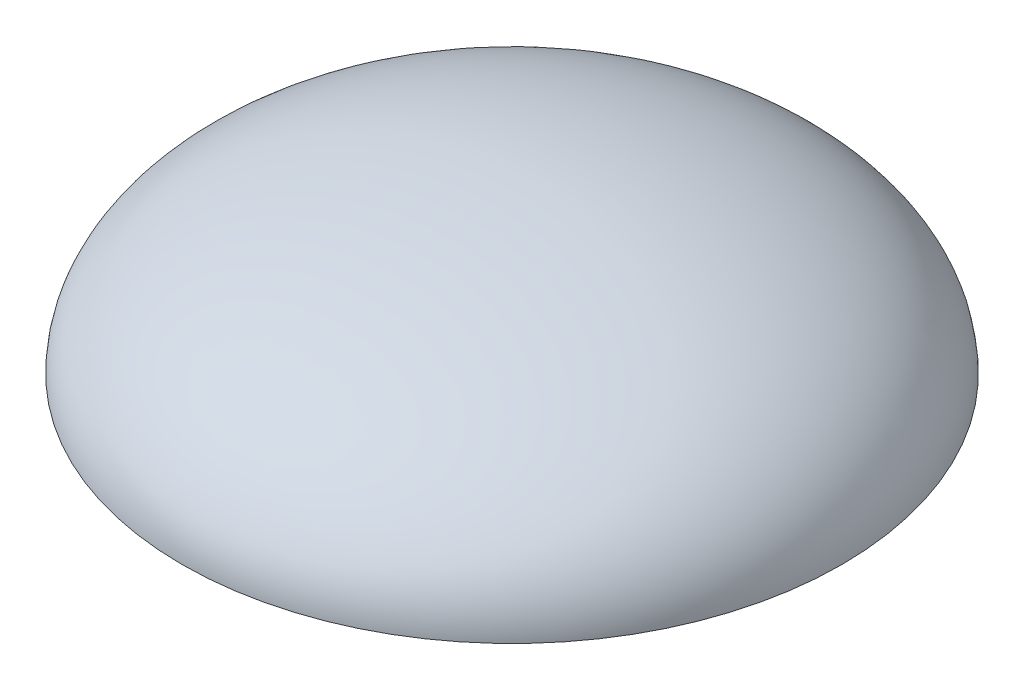
from build123d import *

# Parameters (mm, degrees)
SHELL1_T = -3


with BuildPart() as part:
    # Sketch1 → Revolve1 (revolve)
    with BuildSketch(Plane.XY):
        with BuildLine():
            Line((-13.25, 0), (0, 0))
            Line((0, 0), (0, 6.5))
            add(Edge.make_bspline(
                [(0, 6.5), (-13.25, 6.5), (-13.25, 0)],
                knots=[1.570796327, 1.570796327, 1.570796327, 3.141592654, 3.141592654, 3.141592654], degree=2, weights=[1, 0.707106781, 1]))
        make_face()
    revolve(axis=Axis((0, 6.5, 0), (0, -1, 0)))

    # Shell1
    shell1_openings = [part.faces().sort_by_distance(p)[0] for p in [
        (0, 0, 13.25),
    ]]
    offset(amount=SHELL1_T, openings=shell1_openings, kind=Kind.INTERSECTION)


solid = part.part
